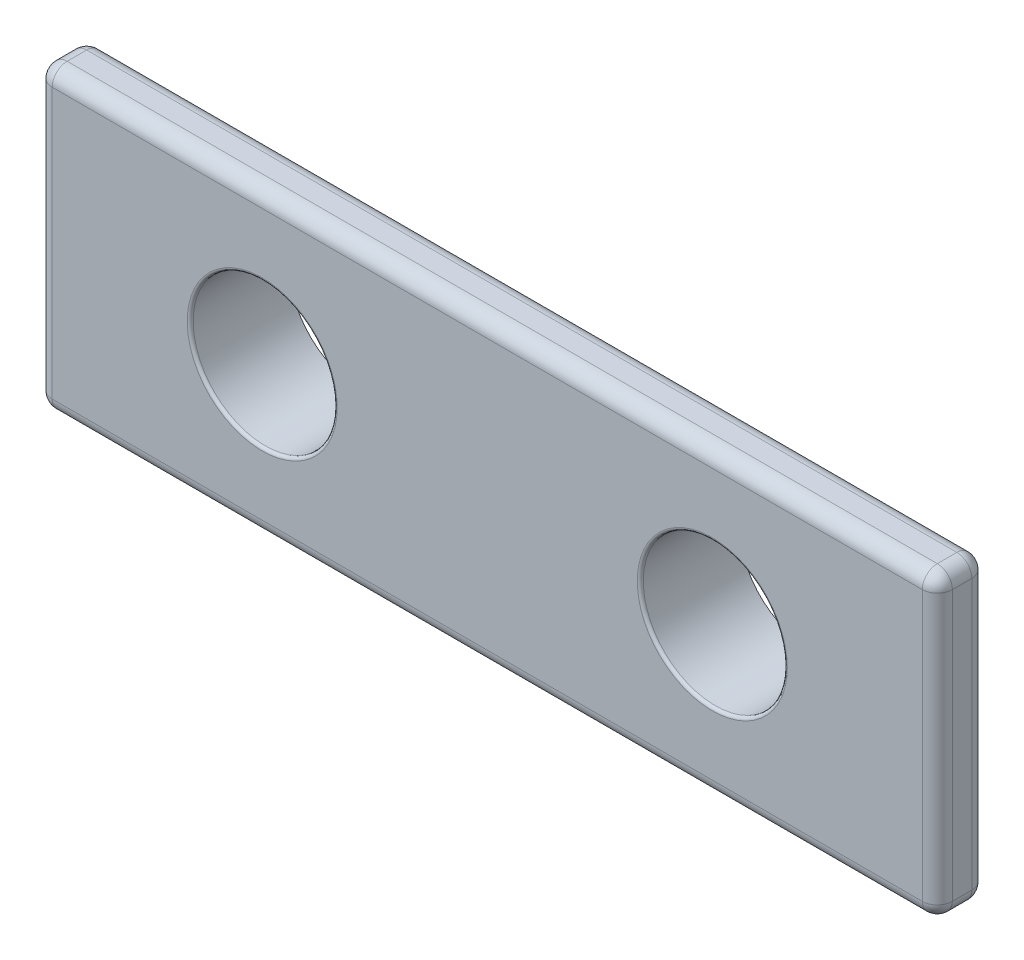
from build123d import *

# Parameters (mm, degrees)
SKETCH1_W            = 30
SKETCH1_H            = 9.998
BOSS_EXTRUDE1_DEPTH  = 1.65
SKETCH2_R            = 2.6
BOSS_EXTRUDE2_DEPTH  = 1.65
SKETCH3_R            = 2.4
CUT_EXTRUDE1_DEPTH   = 4.3
FILLET1_R            = 0.1
FILLET3_R            = 0.5
FILLET4_R            = 0.5
FILLET1_OF_MIRROR2_R = 0.1


with BuildPart() as part:
    # Sketch1 → Boss-Extrude1 (new body)
    with BuildSketch(Plane.XY):
        with Locations((15, 4.999)):
            Rectangle(SKETCH1_W, SKETCH1_H)
    extrude(amount=BOSS_EXTRUDE1_DEPTH)

    # Sketch2 → Boss-Extrude2 (add)
    with BuildSketch(Plane(origin=(0, 0, 0), x_dir=(-1, 0, 0), z_dir=(0, 0, -1))):
        with Locations((-7.5, 4.999)):
            Circle(SKETCH2_R)
    boss_extrude2 = extrude(amount=BOSS_EXTRUDE2_DEPTH)

    # Sketch3 → Cut-Extrude1 (cut, through all)
    with BuildSketch(Plane.XY.offset(1.65)):
        with Locations((7.5, 4.999)):
            Circle(SKETCH3_R)
    cut_extrude1 = extrude(amount=-CUT_EXTRUDE1_DEPTH, mode=Mode.SUBTRACT)

    # Fillet1
    fillet1_edges = [part.edges().sort_by_distance(p)[0] for p in [
        (10.1, 4.999, 0),
        (10.1, 4.999, -1.65),
        (5.1, 4.999, 1.65),
    ]]
    fillet(fillet1_edges, radius=FILLET1_R)

    # Fillet3
    fillet3_edges = [part.edges().sort_by_distance(p)[0] for p in [
        (0, 0, 0.825),
        (0, 9.998, 0.825),
        (30, 9.998, 0.825),
        (30, 0, 0.825),
    ]]
    fillet(fillet3_edges, radius=FILLET3_R)

    # Fillet4
    fillet4_edges = [part.edges().sort_by_distance(p)[0] for p in [
        (15, 9.998, 0),
        (15, 9.998, 1.65),
        (15, 0, 0),
        (0, 4.999, 0),
        (30, 4.999, 0),
        (0.146446609, 0.146446609, 0),
        (0.146446609, 9.851553391, 0),
        (29.853553391, 0.146446609, 0),
        (29.853553391, 9.851553391, 0),
        (30, 4.999, 1.65),
        (15, 0, 1.65),
        (0, 4.999, 1.65),
        (0.146446609, 0.146446609, 1.65),
        (0.146446609, 9.851553391, 1.65),
        (29.853553391, 0.146446609, 1.65),
        (29.853553391, 9.851553391, 1.65),
    ]]
    fillet(fillet4_edges, radius=FILLET4_R)

    # Mirror2: Boss-Extrude2, Cut-Extrude1 across plane
    add(boss_extrude2.mirror(Plane(origin=(15, 0, 0), x_dir=(0, 0, 1), z_dir=(1, 0, 0))))
    add(cut_extrude1.mirror(Plane(origin=(15, 0, 0), x_dir=(0, 0, 1), z_dir=(1, 0, 0))), mode=Mode.SUBTRACT)

    # Fillet1 of Mirror2
    fillet1_of_mirror2_edges = [part.edges().sort_by_distance(p)[0] for p in [
        (19.9, 4.999, 0),
        (19.9, 4.999, -1.65),
        (24.9, 4.999, 1.65),
    ]]
    fillet(fillet1_of_mirror2_edges, radius=FILLET1_OF_MIRROR2_R)


solid = part.part
